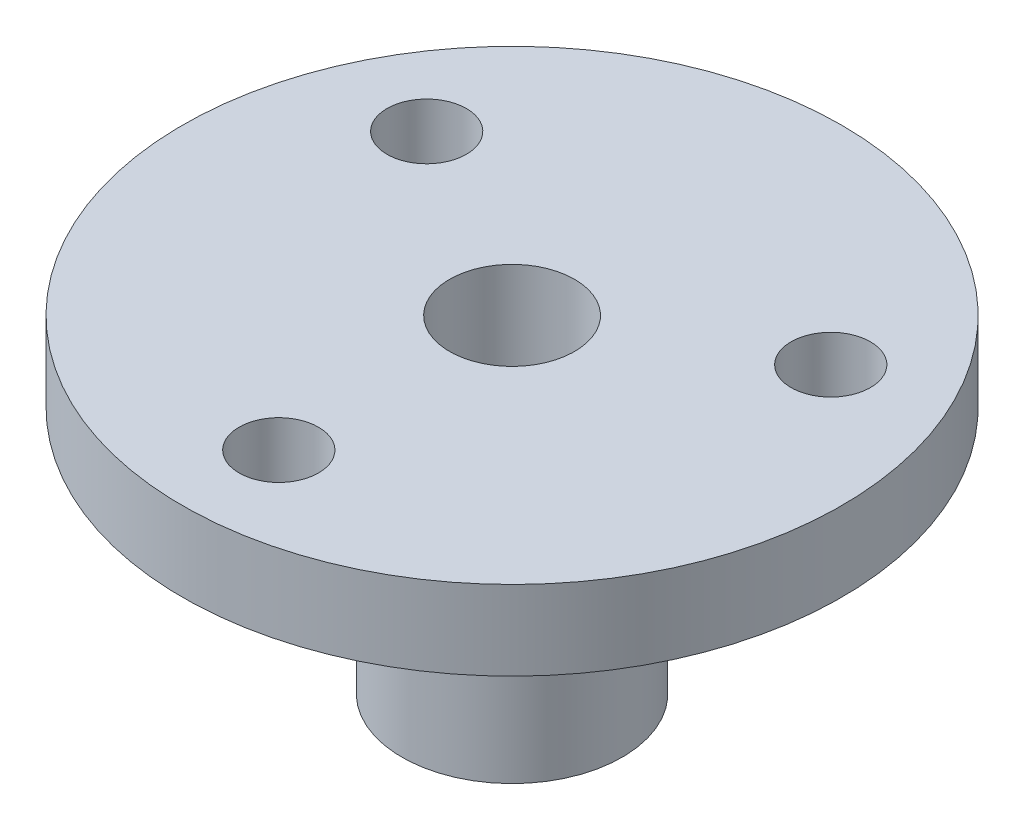
from build123d import *

# Parameters (mm, degrees)
ESQUISSE2_R             = 2
ENL_V_MAT_EXTRU_1_DEPTH = 5


with BuildPart() as part:
    # Esquisse1 → Révolution1 (revolve)
    with BuildSketch(Plane.XY):
        with BuildLine():
            Line((16.6, 16.5), (3.15, 16.5))
            Line((3.15, 16.5), (3.15, 0))
            Line((3.15, 0), (5.55, 0))
            Line((5.55, 0), (5.55, 10))
            ThreePointArc((5.55, 10), (6.282233047, 11.767766953), (8.05, 12.5))
            Line((8.05, 12.5), (16.6, 12.5))
            Line((16.6, 12.5), (16.6, 16.5))
        make_face()
    revolve(axis=Axis((0, 0, 0), (0, 1, 0)))

    # Esquisse2 → Enlèv. mat.-Extru.1 (cut, through all)
    with BuildSketch(Plane.XZ.offset(-12.5)):
        with Locations((0, 11.75)):
            Circle(ESQUISSE2_R)
        with Locations((10.175798494, -5.875)):
            Circle(ESQUISSE2_R)
        with Locations((-10.175798494, -5.875)):
            Circle(ESQUISSE2_R)
    extrude(amount=-ENL_V_MAT_EXTRU_1_DEPTH, mode=Mode.SUBTRACT)


solid = part.part
